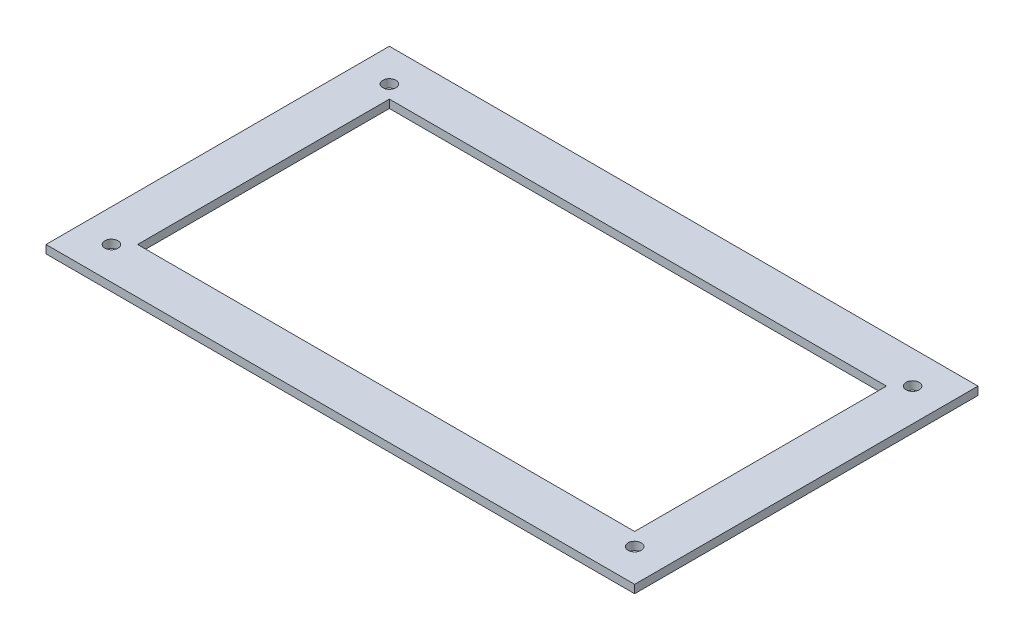
from build123d import *

# Parameters (mm, degrees)
SKETCH1_W           = 360
SKETCH1_H           = 210
SKETCH1_W_2         = 304
SKETCH1_H_2         = 154
BOSS_EXTRUDE1_DEPTH = 5
SKETCH2_R           = 4
CUT_EXTRUDE1_DEPTH  = 10


with BuildPart() as part:
    # Sketch1 → Boss-Extrude1 (new body)
    with BuildSketch(Plane(origin=(0, 0, 0), x_dir=(1, 0, 0), z_dir=(0, 1, 0))):
        Rectangle(SKETCH1_W, SKETCH1_H)
        Rectangle(SKETCH1_W_2, SKETCH1_H_2, mode=Mode.SUBTRACT)
    extrude(amount=BOSS_EXTRUDE1_DEPTH)

    # Sketch2 → Cut-Extrude1 (cut)
    with BuildSketch(Plane(origin=(0, 5, 0), x_dir=(1, 0, 0), z_dir=(0, 1, 0))):
        with Locations((-160, -85)):
            Circle(SKETCH2_R)
        with Locations((160, -85)):
            Circle(SKETCH2_R)
        with Locations((160, 85)):
            Circle(SKETCH2_R)
        with Locations((-160, 85)):
            Circle(SKETCH2_R)
    extrude(amount=-CUT_EXTRUDE1_DEPTH, mode=Mode.SUBTRACT)


solid = part.part
